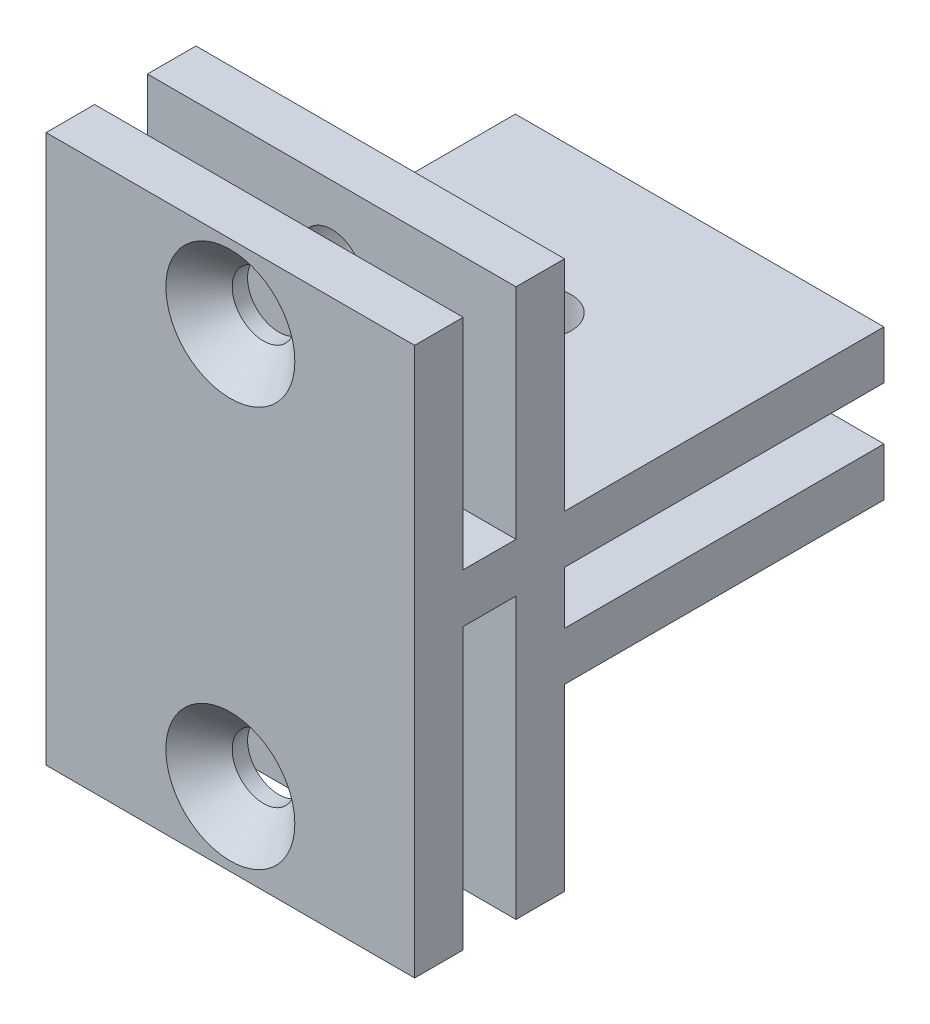
from build123d import *

# Parameters (mm, degrees)
ESQUISSE1_W                                       = 30
ESQUISSE1_H                                       = 44.6
BOSS_EXTRU_1_DEPTH                                = 12.2
ESQUISSE2_W                                       = 30
ESQUISSE2_H                                       = 4.3
ENL_V_MAT_EXTRU_1_DEPTH                           = 17.8
ESQUISSE3_W                                       = 30
ESQUISSE3_H                                       = 4.3
ENL_V_MAT_EXTRU_2_DEPTH                           = 22.8
FRAISAGE_POUR_VIS_T_TE_FRAIS_E_BOMB_E_D           = 5.09999996
FRAISAGE_POUR_VIS_T_TE_FRAIS_E_BOMB_E_CSINK_D     = 10.500000082
FRAISAGE_POUR_VIS_T_TE_FRAIS_E_BOMB_E_CSINK_ANGLE = 90
ESQUISSE6_W                                       = 30
ESQUISSE6_H                                       = 12.2
BOSS_EXTRU_2_DEPTH                                = 26
ESQUISSE7_W                                       = 26
ESQUISSE7_H                                       = 4.3
ENL_V_MAT_EXTRU_3_DEPTH                           = 31
FRAISAGE_POUR_VIS_T_TE_FRAIS_E_BOM_2_D            = 5.09999996
FRAISAGE_POUR_VIS_T_TE_FRAIS_E_BOM_2_CSINK_D      = 10.500000082
FRAISAGE_POUR_VIS_T_TE_FRAIS_E_BOM_2_CSINK_ANGLE  = 90


with BuildPart() as part:
    # Esquisse1 → Boss.-Extru.1 (new body)
    with BuildSketch(Plane.XY):
        with Locations((-26.085427136, 14.986432161)):
            Rectangle(ESQUISSE1_W, ESQUISSE1_H)
    extrude(amount=BOSS_EXTRU_1_DEPTH)

    # Esquisse2 → Enlèv. mat.-Extru.1 (cut)
    with BuildSketch(Plane(origin=(0, 37.286432161, 0), x_dir=(1, 0, 0), z_dir=(0, 1, 0))):
        with Locations((-26.085427136, -6.1)):
            Rectangle(ESQUISSE2_W, ESQUISSE2_H)
    extrude(amount=-ENL_V_MAT_EXTRU_1_DEPTH, mode=Mode.SUBTRACT)

    # Esquisse3 → Enlèv. mat.-Extru.2 (cut)
    with BuildSketch(Plane.XZ.offset(7.313567839)):
        with Locations((-26.085427136, 6.1)):
            Rectangle(ESQUISSE3_W, ESQUISSE3_H)
    extrude(amount=-ENL_V_MAT_EXTRU_2_DEPTH, mode=Mode.SUBTRACT)

    # Fraisage pour vis _ t_te frais_e bomb_e (through all)
    with Locations(Plane(origin=(-26.085427136, -1.313567839, 12.2), x_dir=(1, 0, 0), z_dir=(0, 0, 1))):
        with Locations((0, 0), (0, 32.6)):
            CounterSinkHole(FRAISAGE_POUR_VIS_T_TE_FRAIS_E_BOMB_E_D / 2, FRAISAGE_POUR_VIS_T_TE_FRAIS_E_BOMB_E_CSINK_D / 2, counter_sink_angle=FRAISAGE_POUR_VIS_T_TE_FRAIS_E_BOMB_E_CSINK_ANGLE)

    # Esquisse6 → Boss.-Extru.2 (add)
    with BuildSketch(Plane(origin=(0, 0, 0), x_dir=(-1, 0, 0), z_dir=(0, 0, -1))):
        with Locations((26.085427136, 13.386432161)):
            Rectangle(ESQUISSE6_W, ESQUISSE6_H)
    extrude(amount=BOSS_EXTRU_2_DEPTH)

    # Esquisse7 → Enlèv. mat.-Extru.3 (cut, through all)
    with BuildSketch(Plane.ZY.offset(41.085427136)):
        with Locations((-13, 13.386432161)):
            Rectangle(ESQUISSE7_W, ESQUISSE7_H)
    extrude(amount=-ENL_V_MAT_EXTRU_3_DEPTH, mode=Mode.SUBTRACT)

    # Fraisage pour vis _ t_te frais_e bom 2 (through all)
    with Locations(Plane(origin=(-26.085427136, 7.286432161, -13), x_dir=(-1, 0, 0), z_dir=(0, -1, 0))):
        with Locations((0, 0)):
            CounterSinkHole(FRAISAGE_POUR_VIS_T_TE_FRAIS_E_BOM_2_D / 2, FRAISAGE_POUR_VIS_T_TE_FRAIS_E_BOM_2_CSINK_D / 2, counter_sink_angle=FRAISAGE_POUR_VIS_T_TE_FRAIS_E_BOM_2_CSINK_ANGLE)


solid = part.part
